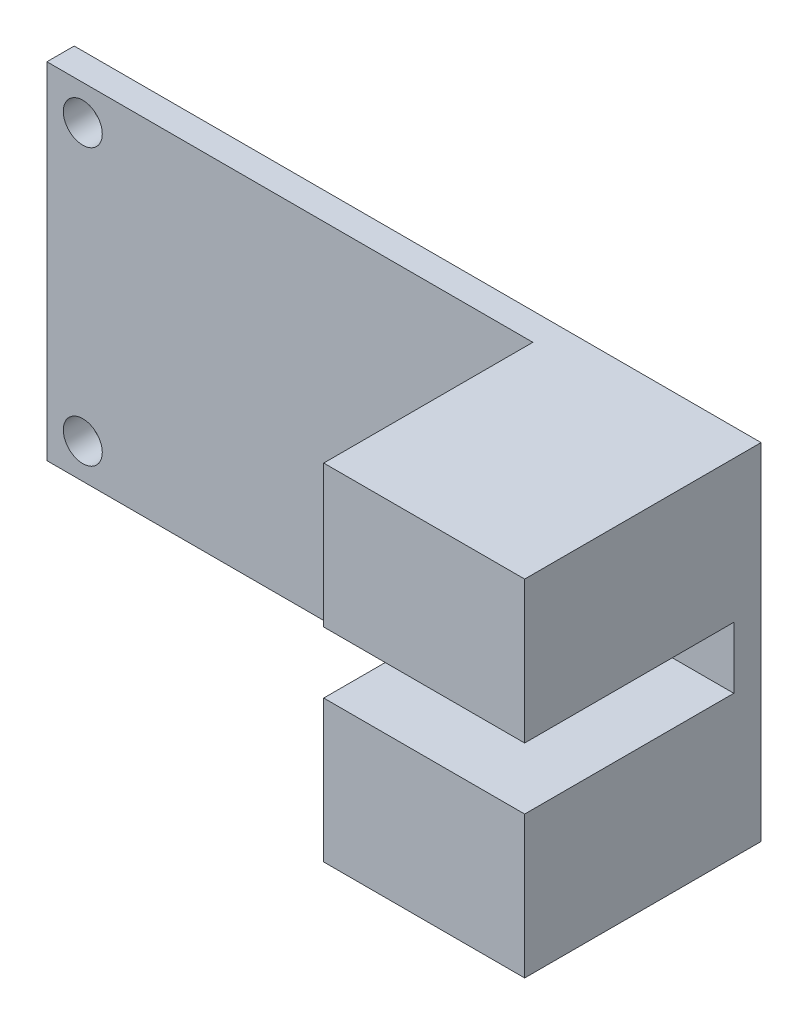
from build123d import *

# Parameters (mm, degrees)
SKETCH1_W           = 33.5
SKETCH1_H           = 16.85
SKETCH1_R           = 0.95
BOSS_EXTRUDE1_DEPTH = 1.33
SKETCH2_W           = 9.8
SKETCH2_H           = 6.925
BOSS_EXTRUDE2_DEPTH = 10.2


with BuildPart() as part:
    # Sketch1 → Boss-Extrude1 (new body)
    with BuildSketch(Plane.XY):
        Rectangle(SKETCH1_W, SKETCH1_H)
        with Locations((-15, -6.725)):
            Circle(SKETCH1_R, mode=Mode.SUBTRACT)
        with Locations((-15, 6.725)):
            Circle(SKETCH1_R, mode=Mode.SUBTRACT)
    extrude(amount=BOSS_EXTRUDE1_DEPTH)

    # Sketch2 → Boss-Extrude2 (add)
    with BuildSketch(Plane.XY.offset(1.33)):
        with Locations((11.85, 4.9625)):
            Rectangle(SKETCH2_W, SKETCH2_H)
        with Locations((11.85, -4.9625)):
            Rectangle(SKETCH2_W, SKETCH2_H)
    extrude(amount=BOSS_EXTRUDE2_DEPTH)


solid = part.part
